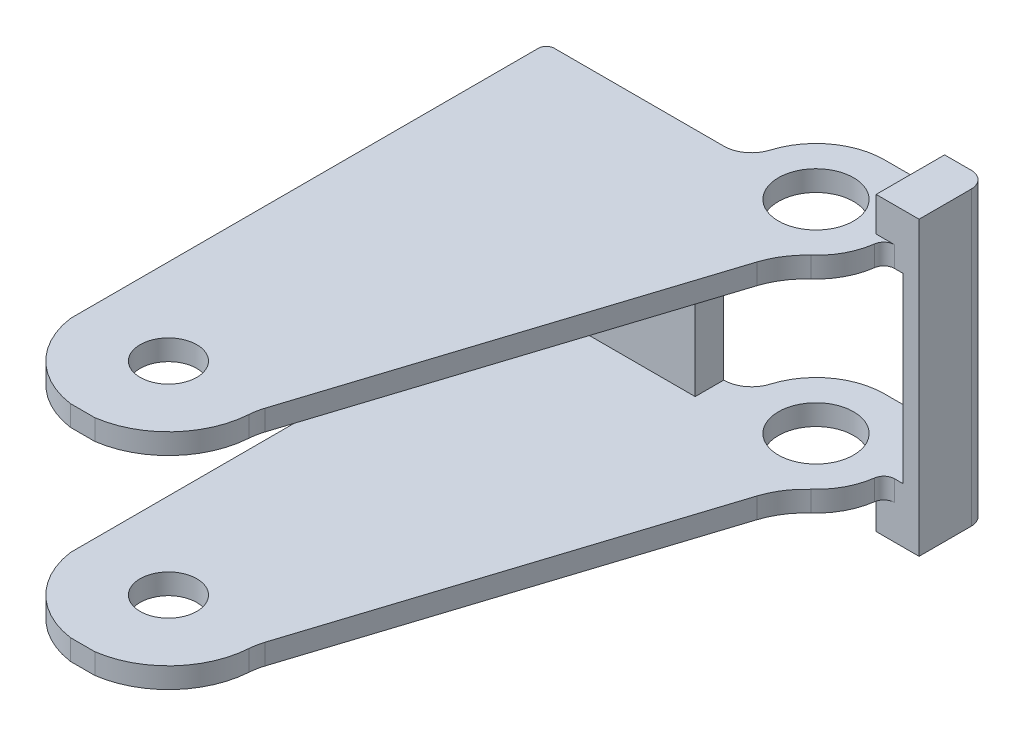
from build123d import *

# Parameters (mm, degrees)
SKETCH1_R               = 4.191
SKETCH1_R_2             = 5.55625
BOSS_EXTRUDE1_DEPTH     = 33.02
CUT_EXTRUDE1_DEPTH      = 56.118
SKETCH3_W               = 26.483565884
SKETCH3_H               = 26.924
CUT_EXTRUDE2_DEPTH      = 11.12825
CUT_EXTRUDE2_DEPTH_BACK = 82.28
BOSS_EXTRUDE2_DEPTH     = 5.08


with BuildPart() as part:
    # Sketch1 → Boss-Extrude1 (new body)
    with BuildSketch(Plane(origin=(0, 0, 0), x_dir=(1, 0, 0), z_dir=(0, 1, 0))):
        with BuildLine():
            ThreePointArc((-27.559, -34.820535754), (-23.929058682, -42.090058682), (-16.659535754, -45.72))
            Line((-16.659535754, -45.72), (-13.058464246, -45.72))
            ThreePointArc((-13.058464246, -45.72), (-5.472288324, -41.761943314), (-2.063174534, -33.91374473))
            ThreePointArc((-2.063174534, -33.91374473), (-1.931764874, -32.906728948), (-1.680693889, -31.922700165))
            Line((-1.680693889, -31.922700165), (5.577256486, -9.252591406))
            Line((5.577256486, -9.252591406), (15.95594723, 23.165107224))
            ThreePointArc((15.95594723, 23.165107224), (17.206676654, 25.810946447), (19.103326913, 28.039736946))
            ThreePointArc((19.103326913, 28.039736946), (21.273883819, 30.828033828), (22.3544782, 34.19229193))
            ThreePointArc((22.3544782, 34.19229193), (22.881358513, 35.169970415), (23.921231105, 35.56))
            Line((23.921231105, 35.56), (27.559, 35.56))
            Line((27.559, 35.56), (27.559, 43.286638959))
            ThreePointArc((27.559, 43.286638959), (26.855584412, 44.984834412), (25.157388959, 45.68825))
            Line((25.157388959, 45.68825), (12.319, 45.68825))
            ThreePointArc((12.319, 45.68825), (6.28241864, 43.692719935), (2.624566002, 38.492472937))
            ThreePointArc((2.624566002, 38.492472937), (1.133892546, 36.373232242), (-1.326176925, 35.56))
            Line((-1.326176925, 35.56), (-26.38140718, 35.56))
            ThreePointArc((-26.38140718, 35.56), (-27.214091048, 35.215091048), (-27.559, 34.38240718))
            Line((-27.559, 34.38240718), (-27.559, -31.219464246))
            Line((-27.559, -31.219464246), (-27.559, -34.820535754))
        make_face()
        with Locations((-14.859, -33.02)):
            Circle(SKETCH1_R, mode=Mode.SUBTRACT)
        with Locations((12.319, 35.56)):
            Circle(SKETCH1_R_2, mode=Mode.SUBTRACT)
    extrude(amount=BOSS_EXTRUDE1_DEPTH)

    # Sketch2 → Cut-Extrude1 (cut, through all)
    with BuildSketch(Plane.ZY.offset(27.559)):
        Polygon((-31.33440718, 29.972), (42.672, 29.972), (45.72, 29.972), (45.72, 3.048), (42.672, 3.048), (-31.33440718, 3.048), align=None)
    extrude(amount=-CUT_EXTRUDE1_DEPTH, mode=Mode.SUBTRACT)

    # Sketch3 → Cut-Extrude2 (cut, two sides)
    with BuildSketch(Plane(origin=(0, 0, -35.56), x_dir=(-1, 0, 0), z_dir=(0, 0, -1))) as cut_extrude2_sk:
        with Locations((-11.915606017, 16.51)):
            Rectangle(SKETCH3_W, SKETCH3_H)
    extrude(amount=CUT_EXTRUDE2_DEPTH, mode=Mode.SUBTRACT)
    extrude(cut_extrude2_sk.sketch, amount=-CUT_EXTRUDE2_DEPTH_BACK, mode=Mode.SUBTRACT)

    # Sketch4 → Boss-Extrude2 (add)
    with BuildSketch(Plane(origin=(0, 33.02, 0), x_dir=(1, 0, 0), z_dir=(0, 1, 0))):
        with BuildLine():
            Line((21.209, 45.68825), (21.209, 35.56))
            Line((21.209, 35.56), (27.559, 35.56))
            Line((27.559, 35.56), (27.559, 43.286638959))
            ThreePointArc((27.559, 43.286638959), (26.855584412, 44.984834412), (25.157388959, 45.68825))
            Line((25.157388959, 45.68825), (21.209, 45.68825))
        make_face()
    boss_extrude2 = extrude(amount=BOSS_EXTRUDE2_DEPTH)

    # Mirror1: Boss-Extrude2 across plane
    add(boss_extrude2.mirror(Plane.ZX.offset(16.51)))


solid = part.part
